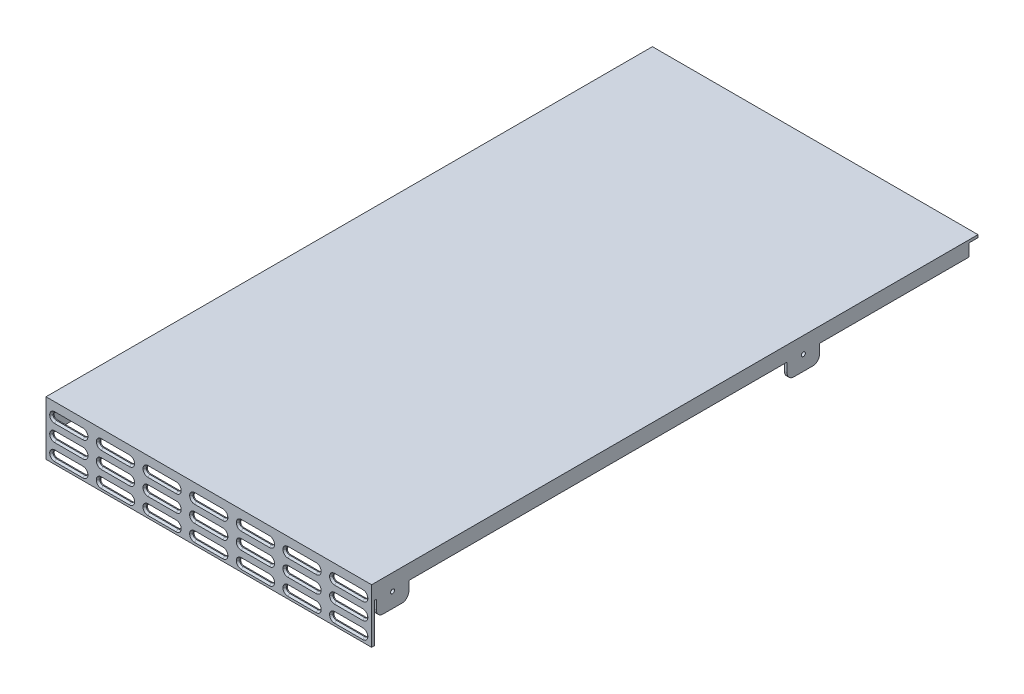
from build123d import *

# Parameters (mm, degrees)
BOSS_EXTRUDE1_DEPTH              = 120.015
SKETCH2_W                        = 0.9906
SKETCH2_H                        = 219.2528
BOSS_EXTRUDE2_DEPTH              = 10.4902
SKETCH3_W                        = 55.118
SKETCH3_H                        = 5.969
CUT_EXTRUDE1_DEPTH               = 120.015
SKETCH4_W                        = 0.7366
SKETCH4_H                        = 5.969
CUT_EXTRUDE2_DEPTH               = 120.015
SKETCH5_W                        = 139.4206
SKETCH5_H                        = 5.969
CUT_EXTRUDE3_DEPTH               = 120.015
E_0_25_DIAMETER_HOLE1_AT_2_COUNT = 2
E_0_25_DIAMETER_HOLE1_AT_2_PITCH = 151.4094
FILLET1_R                        = 2.54
FILLET2_R                        = 2.54
FILLET3_R                        = 2.54
FILLET4_R                        = 2.54
CUT_EXTRUDE4_DEPTH               = 0.9906
CHAMFER1_SIZE                    = 0.635
LPATTERN1_COUNT                  = 7
LPATTERN1_PITCH                  = 17.1958
LPATTERN1_COUNT_DIR2             = 3
LPATTERN1_PITCH_DIR2             = 6.096
CHAMFER1_OF_LPATTERN1_SIZE       = 0.635


with BuildPart() as part:
    # Sketch1 → Boss-Extrude1 (new body)
    with BuildSketch(Plane(origin=(0, 0, 0), x_dir=(0, 0, -1), z_dir=(1, 0, 0))):
        Polygon((0, 0), (0, 19.9898), (223.52, 19.9898), (223.52, 18.9992), (0.9906, 18.9992), (0.9906, 0), align=None)
    extrude(amount=BOSS_EXTRUDE1_DEPTH)

    # Sketch2 → Boss-Extrude2 (add)
    with BuildSketch(Plane.XZ.offset(-18.9992)):
        with Locations((0.4953, -110.617)):
            Rectangle(SKETCH2_W, SKETCH2_H)
    boss_extrude2 = extrude(amount=BOSS_EXTRUDE2_DEPTH)

    # Mirror1: Boss-Extrude2 across plane
    add(boss_extrude2.mirror(Plane.ZY.offset(-60.0075)))

    # Sketch3 → Cut-Extrude1 (cut)
    with BuildSketch(Plane(origin=(120.015, 0, 0), x_dir=(0, 0, -1), z_dir=(1, 0, 0))):
        with Locations((192.6844, 11.4935)):
            Rectangle(SKETCH3_W, SKETCH3_H)
    extrude(amount=-CUT_EXTRUDE1_DEPTH, mode=Mode.SUBTRACT)

    # Sketch4 → Cut-Extrude2 (cut)
    with BuildSketch(Plane(origin=(120.015, 0, 0), x_dir=(0, 0, -1), z_dir=(1, 0, 0))):
        with Locations((1.3589, 11.4935)):
            Rectangle(SKETCH4_W, SKETCH4_H)
    extrude(amount=-CUT_EXTRUDE2_DEPTH, mode=Mode.SUBTRACT)

    # Sketch5 → Cut-Extrude3 (cut)
    with BuildSketch(Plane(origin=(120.015, 0, 0), x_dir=(0, 0, -1), z_dir=(1, 0, 0))):
        with Locations((83.4263, 11.4935)):
            Rectangle(SKETCH5_W, SKETCH5_H)
    extrude(amount=-CUT_EXTRUDE3_DEPTH, mode=Mode.SUBTRACT)

    # Sketch6 → E (0.25) Diameter Hole1 (revolve, cut)
    with BuildSketch(Plane(origin=(120.015, 13.9954, -7.7216), x_dir=(0, 0, -1), z_dir=(0, 1, 0))):
        Polygon((0, 0), (0, 2.228224862), (0.7493, 1.778), (0.7493, 0), align=None)
    e_0_25_diameter_hole1 = revolve(axis=Axis((126.365, 13.9954, -7.7216), (-1, 0, 0)), mode=Mode.SUBTRACT)

    # E (0.25) Diameter Hole1 at 2: E (0.25) Diameter Hole1 ×2
    with Locations(*[(0, 0, -i * E_0_25_DIAMETER_HOLE1_AT_2_PITCH) for i in range(1, E_0_25_DIAMETER_HOLE1_AT_2_COUNT)]):
        add(e_0_25_diameter_hole1, mode=Mode.SUBTRACT)

    # Mirror2: E (0.25) Diameter Hole1 across plane
    add(e_0_25_diameter_hole1.mirror(Plane.ZY.offset(-60.0075)), mode=Mode.SUBTRACT)

    # Mirror2 copy 1 sketch → Mirror2 copy 1 (revolve, cut)
    with BuildSketch(Plane(origin=(0, 13.9954, -159.131), x_dir=(0, 0, -1), z_dir=(0, 1, 0))):
        Polygon((0, 0), (0, -2.228224862), (0.7493, -1.778), (0.7493, 0), align=None)
    revolve(axis=Axis((-6.35, 13.9954, -159.131), (-1, 0, 0)), mode=Mode.SUBTRACT)

    # Fillet1
    fillet1_edges = [part.edges().sort_by_distance(p)[0] for p in [
        (0.4953, 8.509, -153.1366),
        (0.4953, 8.509, -165.1254),
    ]]
    fillet(fillet1_edges, radius=FILLET1_R)

    # Fillet2
    fillet2_edges = [part.edges().sort_by_distance(p)[0] for p in [
        (0.4953, 8.509, -13.716),
        (0.4953, 8.509, -1.7272),
    ]]
    fillet(fillet2_edges, radius=FILLET2_R)

    # Fillet3
    fillet3_edges = [part.edges().sort_by_distance(p)[0] for p in [
        (119.5197, 8.509, -153.1366),
        (119.5197, 8.509, -165.1254),
    ]]
    fillet(fillet3_edges, radius=FILLET3_R)

    # Fillet4
    fillet4_edges = [part.edges().sort_by_distance(p)[0] for p in [
        (119.5197, 8.509, -13.716),
        (119.5197, 8.509, -1.7272),
    ]]
    fillet(fillet4_edges, radius=FILLET4_R)

    # Sketch8 → Cut-Extrude4 (cut)
    with BuildSketch(Plane.XY):
        with BuildLine():
            Line((3.2004, 16.1798), (13.6144, 16.1798))
            ThreePointArc((13.6144, 16.1798), (14.458544075, 15.830144075), (14.8082, 14.986))
            Line((14.8082, 14.986), (14.8082, 14.8844))
            ThreePointArc((14.8082, 14.8844), (14.458544075, 14.040255925), (13.6144, 13.6906))
            Line((13.6144, 13.6906), (3.2004, 13.6906))
            ThreePointArc((3.2004, 13.6906), (2.356255925, 14.040255925), (2.0066, 14.8844))
            Line((2.0066, 14.8844), (2.0066, 14.986))
            ThreePointArc((2.0066, 14.986), (2.356255925, 15.830144075), (3.2004, 16.1798))
        make_face()
    cut_extrude4 = extrude(amount=-CUT_EXTRUDE4_DEPTH, mode=Mode.SUBTRACT)

    # Chamfer1
    chamfer1_edges = [part.edges().sort_by_distance(p)[0] for p in [
        (2.356255925, 15.830144075, 0),
        (2.0066, 14.9352, 0),
        (2.356255925, 14.040255925, 0),
        (8.4074, 13.6906, 0),
        (14.458544075, 14.040255925, 0),
        (14.8082, 14.9352, 0),
        (14.458544075, 15.830144075, 0),
        (8.4074, 16.1798, 0),
    ]]
    chamfer(chamfer1_edges, length=CHAMFER1_SIZE)

    # LPattern1: Cut-Extrude4 7 × 3
    with Locations(*[(i * LPATTERN1_PITCH, -j * LPATTERN1_PITCH_DIR2, 0) for i in range(LPATTERN1_COUNT) for j in range(LPATTERN1_COUNT_DIR2) if (i, j) != (0, 0)]):
        add(cut_extrude4, mode=Mode.SUBTRACT)

    # Chamfer1 of LPattern1
    chamfer1_of_lpattern1_edges = [part.edges().sort_by_distance(p)[0] for p in [
        (2.356255925, 9.734144075, 0),
        (2.0066, 8.8392, 0),
        (2.356255925, 7.944255925, 0),
        (8.4074, 7.5946, 0),
        (14.458544075, 7.944255925, 0),
        (14.8082, 8.8392, 0),
        (14.458544075, 9.734144075, 0),
        (8.4074, 10.0838, 0),
        (2.356255925, 3.638144075, 0),
        (2.0066, 2.7432, 0),
        (2.356255925, 1.848255925, 0),
        (8.4074, 1.4986, 0),
        (14.458544075, 1.848255925, 0),
        (14.8082, 2.7432, 0),
        (14.458544075, 3.638144075, 0),
        (8.4074, 3.9878, 0),
        (19.552055925, 15.830144075, 0),
        (19.2024, 14.9352, 0),
        (19.552055925, 14.040255925, 0),
        (25.6032, 13.6906, 0),
        (31.654344075, 14.040255925, 0),
        (32.004, 14.9352, 0),
        (31.654344075, 15.830144075, 0),
        (25.6032, 16.1798, 0),
        (19.552055925, 9.734144075, 0),
        (19.2024, 8.8392, 0),
        (19.552055925, 7.944255925, 0),
        (25.6032, 7.5946, 0),
        (31.654344075, 7.944255925, 0),
        (32.004, 8.8392, 0),
        (31.654344075, 9.734144075, 0),
        (25.6032, 10.0838, 0),
        (19.552055925, 3.638144075, 0),
        (19.2024, 2.7432, 0),
        (19.552055925, 1.848255925, 0),
        (25.6032, 1.4986, 0),
        (31.654344075, 1.848255925, 0),
        (32.004, 2.7432, 0),
        (31.654344075, 3.638144075, 0),
        (25.6032, 3.9878, 0),
        (36.747855925, 15.830144075, 0),
        (36.3982, 14.9352, 0),
        (36.747855925, 14.040255925, 0),
        (42.799, 13.6906, 0),
        (48.850144075, 14.040255925, 0),
        (49.1998, 14.9352, 0),
        (48.850144075, 15.830144075, 0),
        (42.799, 16.1798, 0),
        (36.747855925, 9.734144075, 0),
        (36.3982, 8.8392, 0),
        (36.747855925, 7.944255925, 0),
        (42.799, 7.5946, 0),
        (48.850144075, 7.944255925, 0),
        (49.1998, 8.8392, 0),
        (48.850144075, 9.734144075, 0),
        (42.799, 10.0838, 0),
        (36.747855925, 3.638144075, 0),
        (36.3982, 2.7432, 0),
        (36.747855925, 1.848255925, 0),
        (42.799, 1.4986, 0),
        (48.850144075, 1.848255925, 0),
        (49.1998, 2.7432, 0),
        (48.850144075, 3.638144075, 0),
        (42.799, 3.9878, 0),
        (53.943655925, 15.830144075, 0),
        (53.594, 14.9352, 0),
        (53.943655925, 14.040255925, 0),
        (59.9948, 13.6906, 0),
        (66.045944075, 14.040255925, 0),
        (66.3956, 14.9352, 0),
        (66.045944075, 15.830144075, 0),
        (59.9948, 16.1798, 0),
        (53.943655925, 9.734144075, 0),
        (53.594, 8.8392, 0),
        (53.943655925, 7.944255925, 0),
        (59.9948, 7.5946, 0),
        (66.045944075, 7.944255925, 0),
        (66.3956, 8.8392, 0),
        (66.045944075, 9.734144075, 0),
        (59.9948, 10.0838, 0),
        (53.943655925, 3.638144075, 0),
        (53.594, 2.7432, 0),
        (53.943655925, 1.848255925, 0),
        (59.9948, 1.4986, 0),
        (66.045944075, 1.848255925, 0),
        (66.3956, 2.7432, 0),
        (66.045944075, 3.638144075, 0),
        (59.9948, 3.9878, 0),
        (71.139455925, 15.830144075, 0),
        (70.7898, 14.9352, 0),
        (71.139455925, 14.040255925, 0),
        (77.1906, 13.6906, 0),
        (83.241744075, 14.040255925, 0),
        (83.5914, 14.9352, 0),
        (83.241744075, 15.830144075, 0),
        (77.1906, 16.1798, 0),
        (71.139455925, 9.734144075, 0),
        (70.7898, 8.8392, 0),
        (71.139455925, 7.944255925, 0),
        (77.1906, 7.5946, 0),
        (83.241744075, 7.944255925, 0),
        (83.5914, 8.8392, 0),
        (83.241744075, 9.734144075, 0),
        (77.1906, 10.0838, 0),
        (71.139455925, 3.638144075, 0),
        (70.7898, 2.7432, 0),
        (71.139455925, 1.848255925, 0),
        (77.1906, 1.4986, 0),
        (83.241744075, 1.848255925, 0),
        (83.5914, 2.7432, 0),
        (83.241744075, 3.638144075, 0),
        (77.1906, 3.9878, 0),
        (88.335255925, 15.830144075, 0),
        (87.9856, 14.9352, 0),
        (88.335255925, 14.040255925, 0),
        (94.3864, 13.6906, 0),
        (100.437544075, 14.040255925, 0),
        (100.7872, 14.9352, 0),
        (100.437544075, 15.830144075, 0),
        (94.3864, 16.1798, 0),
        (88.335255925, 9.734144075, 0),
        (87.9856, 8.8392, 0),
        (88.335255925, 7.944255925, 0),
        (94.3864, 7.5946, 0),
        (100.437544075, 7.944255925, 0),
        (100.7872, 8.8392, 0),
        (100.437544075, 9.734144075, 0),
        (94.3864, 10.0838, 0),
        (88.335255925, 3.638144075, 0),
        (87.9856, 2.7432, 0),
        (88.335255925, 1.848255925, 0),
        (94.3864, 1.4986, 0),
        (100.437544075, 1.848255925, 0),
        (100.7872, 2.7432, 0),
        (100.437544075, 3.638144075, 0),
        (94.3864, 3.9878, 0),
        (105.531055925, 15.830144075, 0),
        (105.1814, 14.9352, 0),
        (105.531055925, 14.040255925, 0),
        (111.5822, 13.6906, 0),
        (117.633344075, 14.040255925, 0),
        (117.983, 14.9352, 0),
        (117.633344075, 15.830144075, 0),
        (111.5822, 16.1798, 0),
        (105.531055925, 9.734144075, 0),
        (105.1814, 8.8392, 0),
        (105.531055925, 7.944255925, 0),
        (111.5822, 7.5946, 0),
        (117.633344075, 7.944255925, 0),
        (117.983, 8.8392, 0),
        (117.633344075, 9.734144075, 0),
        (111.5822, 10.0838, 0),
        (105.531055925, 3.638144075, 0),
        (105.1814, 2.7432, 0),
        (105.531055925, 1.848255925, 0),
        (111.5822, 1.4986, 0),
        (117.633344075, 1.848255925, 0),
        (117.983, 2.7432, 0),
        (117.633344075, 3.638144075, 0),
        (111.5822, 3.9878, 0),
    ]]
    chamfer(chamfer1_of_lpattern1_edges, length=CHAMFER1_OF_LPATTERN1_SIZE)


solid = part.part
